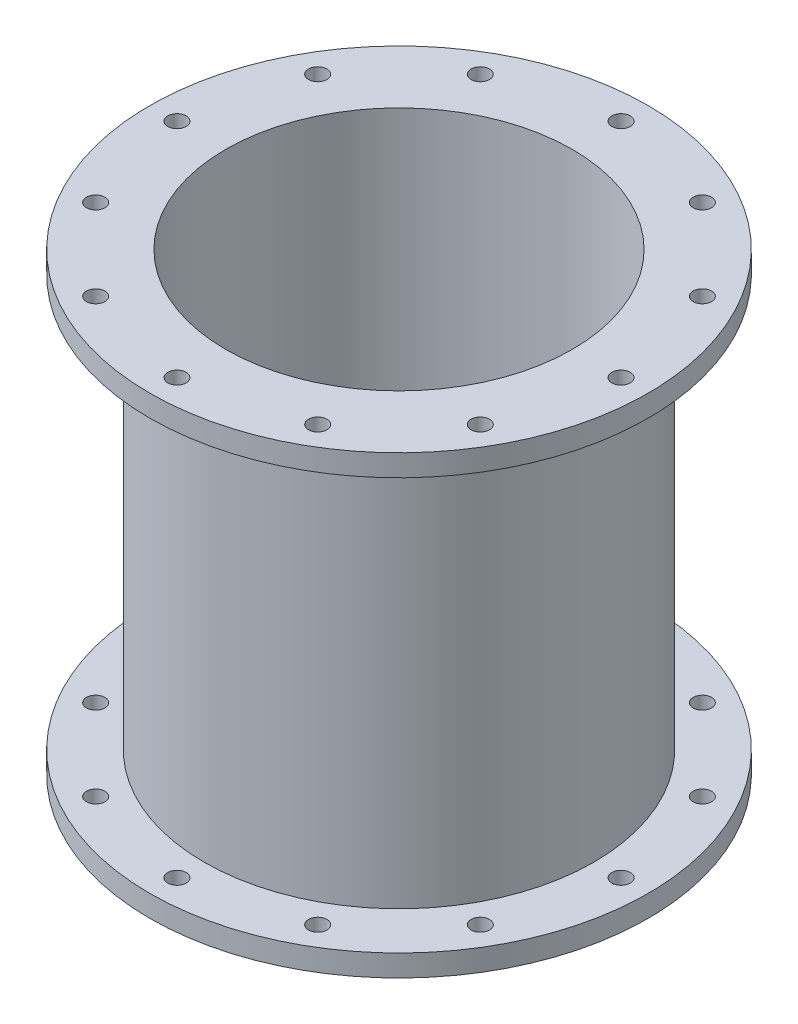
from build123d import *

# Parameters (mm, degrees)
M3_CLEARANCE_HOLE1_D     = 3.4
M3_CLEARANCE_HOLE1_DEPTH = 4.001
M3_CLEARANCE_HOLE2_D     = 3.4
M3_CLEARANCE_HOLE2_DEPTH = 4.001
CIRPATTERN1_COUNT        = 12


with BuildPart() as part:
    # Sketch1 → Revolve1 (revolve)
    with BuildSketch(Plane.XY):
        Polygon((-32, 83.984026871), (-32, 0), (-46, 0), (-46, 4), (-36, 4), (-36, 79.984026871), (-46, 79.984026871), (-46, 83.984026871), align=None)
    revolve(axis=Axis((0, 0, 0), (0, 1, 0)))

    # M3 Clearance Hole1
    with Locations(Plane(origin=(0, 83.984026871, 0), x_dir=(1, 0, 0), z_dir=(0, 1, 0))):
        with Locations((0, 41)):
            m3_clearance_hole1 = Hole(M3_CLEARANCE_HOLE1_D / 2, depth=M3_CLEARANCE_HOLE1_DEPTH)

    # M3 Clearance Hole2
    with Locations(Plane(origin=(0, 0, 0), x_dir=(-1, 0, 0), z_dir=(0, -1, 0))):
        with Locations((0, 41)):
            m3_clearance_hole2 = Hole(M3_CLEARANCE_HOLE2_D / 2, depth=M3_CLEARANCE_HOLE2_DEPTH)

    # CirPattern1: M3 Clearance Hole1, M3 Clearance Hole2 ×12 about axis
    cirpattern1_axis = Axis((0, 0, 0), (0, 1, 0))
    for i in range(1, CIRPATTERN1_COUNT):
        add(m3_clearance_hole1.rotate(cirpattern1_axis, i * 360 / CIRPATTERN1_COUNT), mode=Mode.SUBTRACT)
        add(m3_clearance_hole2.rotate(cirpattern1_axis, i * 360 / CIRPATTERN1_COUNT), mode=Mode.SUBTRACT)


solid = part.part
